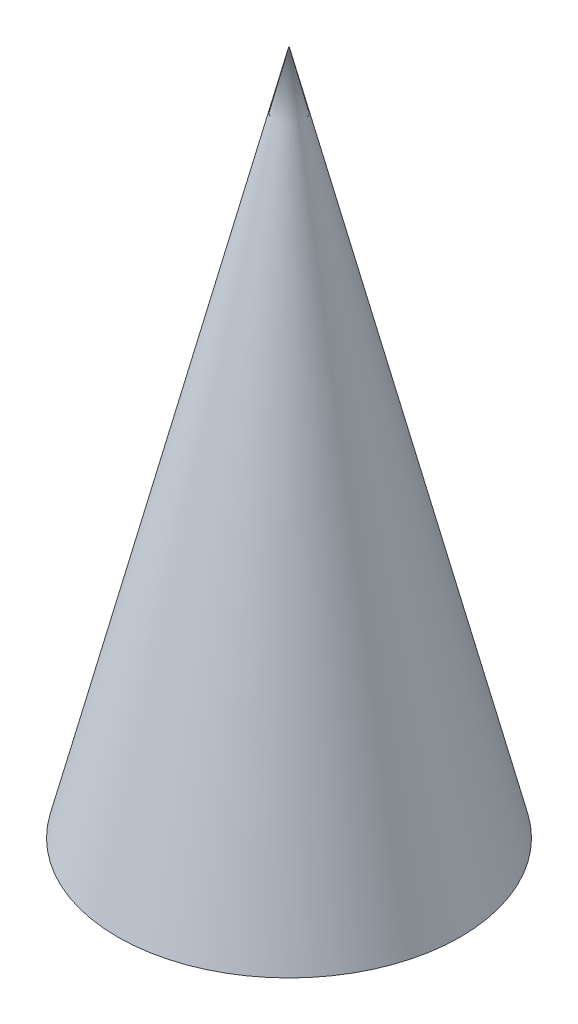
from build123d import *

# Parameters (mm, degrees)
SKETCH1_R = 5


with BuildPart() as part:
    # Sketch1 → Loft1 section 0
    with BuildSketch(Plane(origin=(0, 0, 0), x_dir=(1, 0, 0), z_dir=(0, 1, 0)), mode=Mode.PRIVATE) as loft1_s0:
        Circle(SKETCH1_R)
    loft([Vertex(0, 20, 0), loft1_s0.sketch])


solid = part.part
